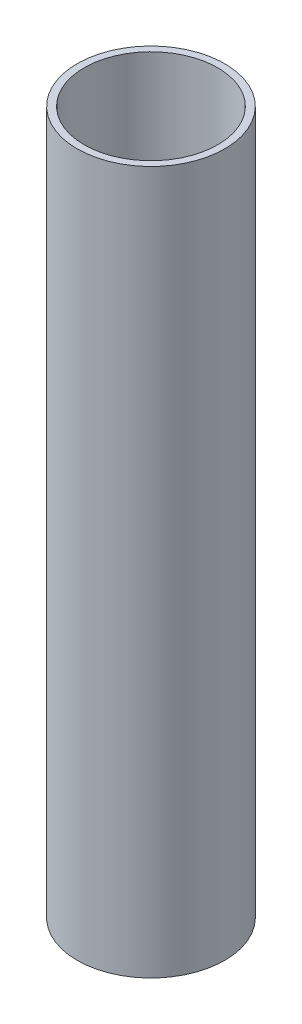
from build123d import *

# Parameters (mm, degrees)
SKETCH1_R           = 10.5
SKETCH1_R_2         = 9.5
BOSS_EXTRUDE1_DEPTH = 100


with BuildPart() as part:
    # Sketch1 → Boss-Extrude1 (new body)
    with BuildSketch(Plane(origin=(0, 0, 0), x_dir=(1, 0, 0), z_dir=(0, 1, 0))):
        Circle(SKETCH1_R)
        Circle(SKETCH1_R_2, mode=Mode.SUBTRACT)
    extrude(amount=BOSS_EXTRUDE1_DEPTH)


solid = part.part
